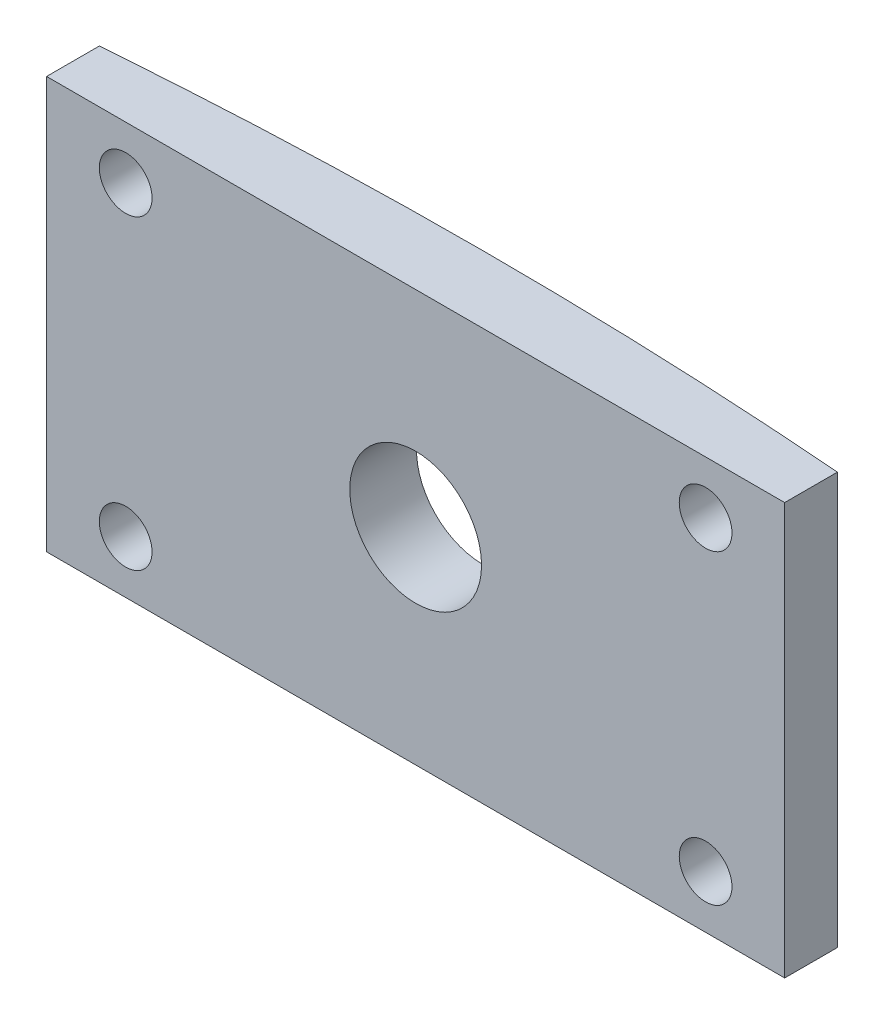
from build123d import *

# Parameters (mm, degrees)
BOSS_EXTRUDE1_DEPTH = 156.2
SKETCH2_R           = 10
SKETCH2_R_2         = 25
CUT_EXTRUDE1_DEPTH  = 26.525992736


with BuildPart() as part:
    # Sketch1 → Boss-Extrude1 (new body)
    with BuildSketch(Plane(origin=(0, 0, 0), x_dir=(1, 0, 0), z_dir=(0, 1, 0))):
        with BuildLine():
            Line((-140, 0), (-140, -20))
            Line((-140, -20), (140, -20))
            Line((140, -20), (140, 0))
            ThreePointArc((140, 0), (0, 5.525992736), (-140, 0))
        make_face()
    extrude(amount=BOSS_EXTRUDE1_DEPTH)

    # Sketch2 → Cut-Extrude1 (cut, through all)
    with BuildSketch(Plane.XY.offset(20)):
        with Locations((-110, 136.2)):
            Circle(SKETCH2_R)
        with Locations((-110, 20)):
            Circle(SKETCH2_R)
        with Locations((110, 20)):
            Circle(SKETCH2_R)
        with Locations((110, 136.2)):
            Circle(SKETCH2_R)
        with Locations((0, 78.1)):
            Circle(SKETCH2_R_2)
    extrude(amount=-CUT_EXTRUDE1_DEPTH, mode=Mode.SUBTRACT)


solid = part.part
